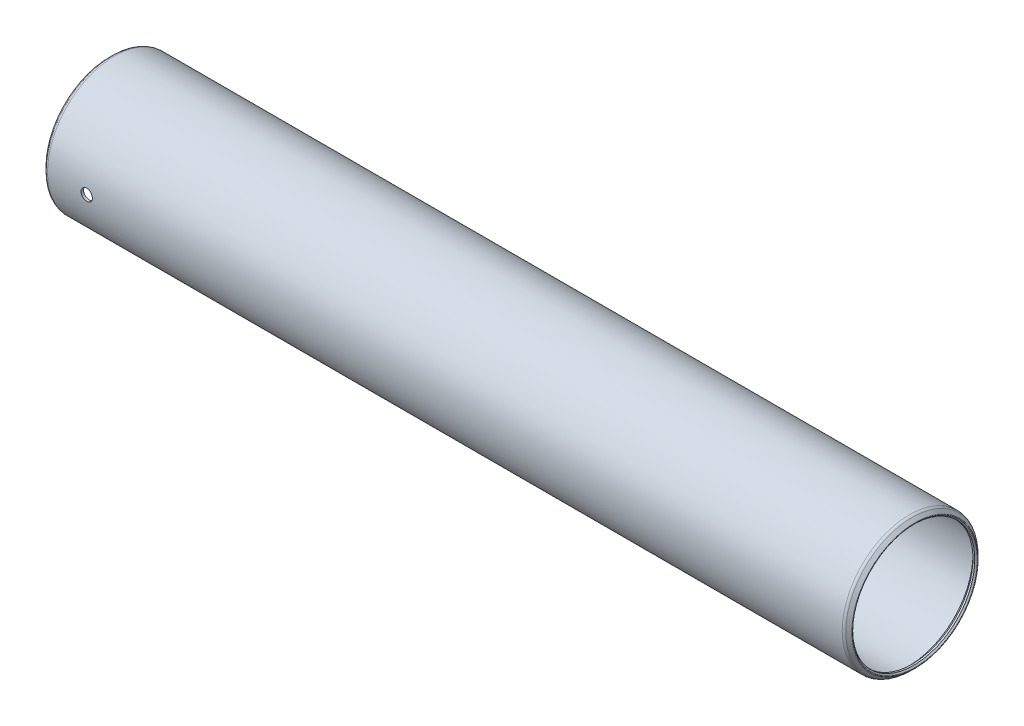
from build123d import *

# Parameters (mm, degrees)
SKETCH2_R          = 1.1938
CUT_EXTRUDE1_DEPTH = 14.1351


with BuildPart() as part:
    # Sketch1 → Revolve1 (revolve)
    with BuildSketch(Plane.XY):
        with BuildLine():
            Line((-0.639512806, 13.104562806), (-0.381, 12.84605))
            Line((-0.381, 12.84605), (0, 12.84605))
            Line((0, 12.84605), (0.762, 13.60805))
            Line((0.762, 13.60805), (167.4114, 13.60805))
            Line((167.4114, 13.60805), (168.1734, 12.84605))
            Line((168.1734, 12.84605), (168.5544, 12.84605))
            Line((168.5544, 12.84605), (168.812912806, 13.104562806))
            ThreePointArc((168.812912806, 13.104562806), (168.850110245, 13.194365367), (168.812912806, 13.284167928))
            Line((168.812912806, 13.284167928), (168.185165367, 13.911915367))
            ThreePointArc((168.185165367, 13.911915367), (167.937954775, 14.077096204), (167.64635, 14.1351))
            Line((167.64635, 14.1351), (0.52705, 14.1351))
            ThreePointArc((0.52705, 14.1351), (0.235445225, 14.077096204), (-0.011765367, 13.911915367))
            Line((-0.011765367, 13.911915367), (-0.639512806, 13.284167928))
            ThreePointArc((-0.639512806, 13.284167928), (-0.676710245, 13.194365367), (-0.639512806, 13.104562806))
        make_face()
    revolve(axis=Axis((168.1734, 0, 0), (-1, 0, 0)))

    # Sketch2 → Cut-Extrude1 (cut)
    with BuildSketch(Plane.XY):
        with Locations((8.763, 0)):
            Circle(SKETCH2_R)
    extrude(amount=CUT_EXTRUDE1_DEPTH, mode=Mode.SUBTRACT)


solid = part.part
